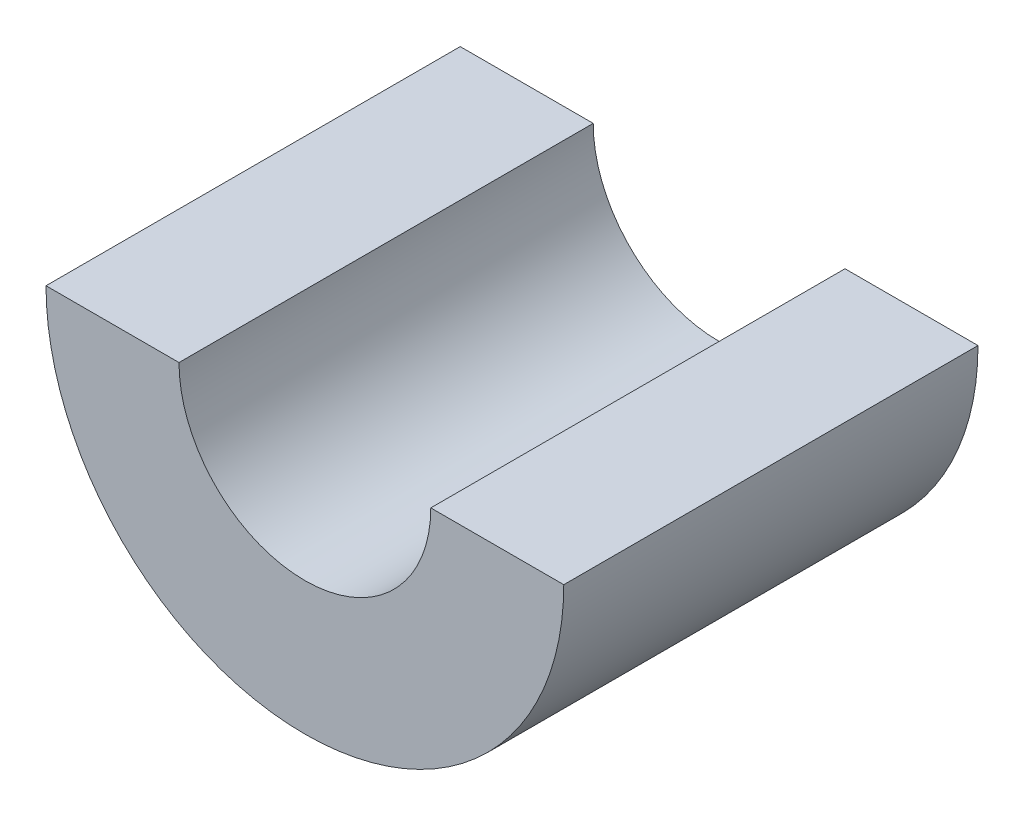
from build123d import *

# Parameters (mm, degrees)
BOSS_EXTRUDE1_DEPTH = 8


with BuildPart() as part:
    # Sketch1 → Boss-Extrude1 (new body)
    with BuildSketch(Plane.XY):
        with BuildLine():
            Line((5, 0), (2.43137085, 0))
            ThreePointArc((2.43137085, 0), (0, -2.43137085), (-2.43137085, 0))
            Line((-2.43137085, 0), (-5, 0))
            ThreePointArc((-5, 0), (0, -5), (5, 0))
        make_face()
    extrude(amount=BOSS_EXTRUDE1_DEPTH)


solid = part.part
